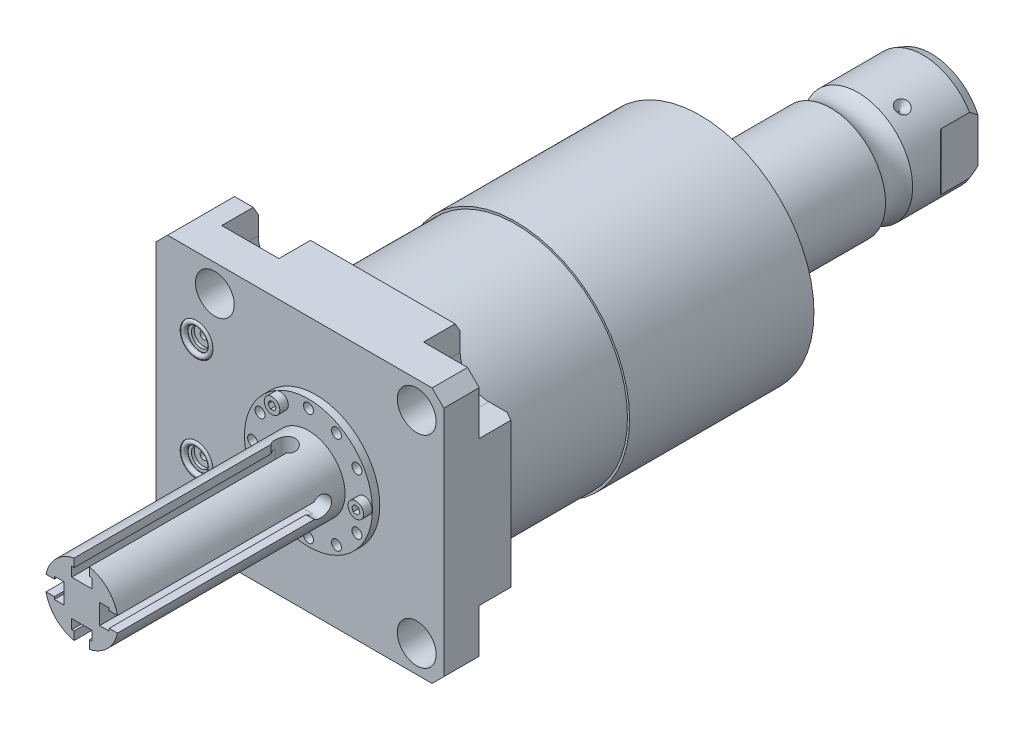
from build123d import *

# Parameters (mm, degrees)
SKETCH1_W                   = 100
SKETCH1_H                   = 88.9
EXTRUDE1_DEPTH              = 25.019
HOLE1_D                     = 13.487
CUT_EXTRUDE2_DEPTH          = 12.7
SKETCH6_R                   = 5.7023
CUT_EXTRUDE3_DEPTH          = 1.4478
SKETCH7_R                   = 3.2512
CUT_EXTRUDE4_DEPTH          = 1.016
SKETCH8_R                   = 1.2446
CUT_EXTRUDE5_DEPTH          = 11.9888
SKETCH9_R                   = 0.9271
CHAMFER1_SIZE               = 4.064
CHAMFER2_SIZE               = 3.0226
CHAMFER2_SIZE2              = 1.745098924
CIRPATTERN1_COUNT           = 3
CUT_EXTRUDE8_DEPTH          = 45.45
CUT_EXTRUDE8_DEPTH_BACK     = 45.45
SKETCH36_R                  = 1.727203455
SKETCH36_R_2                = 1.727203454
CUT_EXTRUDE9_DEPTH          = 2.540005
SKETCH37_R                  = 2.70510541
EXTRUDE2_DEPTH              = 2.946405893
CUT_EXTRUDE10_DEPTH         = 2.032004064
CUT_EXTRUDE11_DEPTH         = 6.477012954
SKETCH40_W                  = 6.98501397
SKETCH40_H                  = 70.612
CUT_EXTRUDE12_DEPTH         = 3.302006604
CIRPATTERN2_COUNT           = 2
CIRPATTERN2_ANGLE           = 90
CIRPATTERN2_COPY_1_DEPTH    = 6.477012954
CIRPATTERN2_COPY_2_SKETCH_W = 6.98501397
CIRPATTERN2_COPY_2_SKETCH_H = 70.612
CIRPATTERN2_COPY_2_DEPTH    = 3.302006604


with BuildPart() as part:
    # Sketch1 → Extrude1 (new body)
    with BuildSketch(Plane.XY):
        with Locations((-5.55, 0)):
            Rectangle(SKETCH1_W, SKETCH1_H)
    extrude(amount=EXTRUDE1_DEPTH)

    # Hole1 (through all)
    with Locations(Plane(origin=(0, 0, 0), x_dir=(-1, 0, 0), z_dir=(0, 0, -1))):
        with Locations((-35.052, -35.052), (-35.052, 35.052), (35.052, 35.052), (35.052, -35.052)):
            Hole(HOLE1_D / 2)

    # Sketch3 → Cut-Extrude2 (cut)
    with BuildSketch(Plane(origin=(0, 0, 0), x_dir=(-1, 0, 0), z_dir=(0, 0, -1))):
        with BuildLine():
            Line((-35.052, -25.1205), (-44.45, -25.1205))
            Line((-44.45, -25.1205), (-44.45, -44.45))
            Line((-44.45, -44.45), (-25.1205, -44.45))
            Line((-25.1205, -44.45), (-25.1205, -35.052))
            ThreePointArc((-25.1205, -35.052), (-28.029369003, -28.029369003), (-35.052, -25.1205))
        make_face()
        with BuildLine():
            Line((-44.45, 25.1205), (-44.45, 44.45))
            Line((-44.45, 44.45), (-25.1205, 44.45))
            Line((-25.1205, 44.45), (-25.1205, 35.052))
            ThreePointArc((-25.1205, 35.052), (-28.029369003, 28.029369003), (-35.052, 25.1205))
            Line((-35.052, 25.1205), (-44.45, 25.1205))
        make_face()
        with BuildLine():
            Line((25.1205, 44.45), (25.1205, 35.052))
            ThreePointArc((25.1205, 35.052), (35.052, 25.1205), (44.9835, 35.052))
            Line((44.9835, 35.052), (44.9835, 44.45))
            Line((44.9835, 44.45), (25.1205, 44.45))
        make_face()
        with BuildLine():
            Line((44.9835, -44.45), (25.1205, -44.45))
            Line((25.1205, -44.45), (25.1205, -35.052))
            ThreePointArc((25.1205, -35.052), (35.052, -25.1205), (44.9835, -35.052))
            Line((44.9835, -35.052), (44.9835, -44.45))
        make_face()
    extrude(amount=-CUT_EXTRUDE2_DEPTH, mode=Mode.SUBTRACT)

    # Sketch23 → Cut-Revolve5 (revolve, cut)
    with BuildSketch(Plane.XY.offset(12.014), mode=Mode.PRIVATE) as cut_revolve5_sk:
        Polygon((-55.55, -23.749), (-55.296, -23.749), (-55.296, -19.6596), (-54.5848, -18.9484), (-41.1228, -18.9484), (-41.1228, -13.0048), (-55.55, -13.0048), align=None)
    cut_revolve5 = revolve(cut_revolve5_sk.sketch.rotate(Axis((-11.939660979, -13.0048, 12.014), (-1, 0, 0)), 180), axis=Axis((-11.939660979, -13.0048, 12.014), (-1, 0, 0)), mode=Mode.SUBTRACT)  # turned: the seam where the file's is

    # Mirror1: Cut-Revolve5 across plane
    add(cut_revolve5.mirror(Plane.ZX), mode=Mode.SUBTRACT)

    # Sketch6 → Cut-Extrude3 (cut)
    with BuildSketch(Plane.XY.offset(25.019)):
        with Locations((-41.402, -18.11)):
            Circle(SKETCH6_R)
        with Locations((-41.402, 18.11)):
            Circle(SKETCH6_R)
    extrude(amount=-CUT_EXTRUDE3_DEPTH, mode=Mode.SUBTRACT)

    # Sketch7 → Cut-Extrude4 (cut)
    with BuildSketch(Plane.XY.offset(23.5712)):
        with Locations((-41.402, 18.11)):
            Circle(SKETCH7_R)
        with Locations((-41.402, -18.11)):
            Circle(SKETCH7_R)
    extrude(amount=-CUT_EXTRUDE4_DEPTH, mode=Mode.SUBTRACT)

    # Sketch8 → Cut-Extrude5 (cut)
    with BuildSketch(Plane.XY.offset(22.5552)):
        with Locations((-41.402, 18.11)):
            Circle(SKETCH8_R)
        with Locations((-41.402, -18.11)):
            Circle(SKETCH8_R)
    extrude(amount=-CUT_EXTRUDE5_DEPTH, mode=Mode.SUBTRACT)

    # Chamfer1
    chamfer1_edges = [part.edges().sort_by_distance(p)[0] for p in [
        (-55.55, 44.45, 12.5095),
        (44.45, 44.45, 18.8595),
        (44.45, -44.45, 18.8595),
        (-55.55, -44.45, 12.5095),
    ]]
    chamfer(chamfer1_edges, length=CHAMFER1_SIZE)

    # Chamfer2
    chamfer2_edges = [part.edges().sort_by_distance(p)[0] for p in [
        (-48.23475, -44.45, 0),
        (44.45, 0, 0),
        (0, 44.45, 0),
        (-48.23475, 44.45, 0),
        (0, -44.45, 0),
    ]]
    chamfer2_side = [part.faces().sort_by_distance(p)[0] for p in [
        (-6.590555374, 0, 0),
    ]]
    chamfer(chamfer2_edges, length=CHAMFER2_SIZE, length2=CHAMFER2_SIZE2, reference=chamfer2_side[0])

    # Sketch24 → Revolve4 (revolve)
    with BuildSketch(Plane(origin=(0, 0, 0), x_dir=(0, 0, -1), z_dir=(1, 0, 0)), mode=Mode.PRIVATE) as revolve4_sk:
        Polygon((0, 0), (0, 38.786), (44.45, 38.786), (44.45, 39.5225), (108.48388753, 39.5225), (112.268, 25.4), (112.268, 0), align=None)
    revolve(revolve4_sk.sketch.rotate(Axis((0, 0, 0), (0, 0, -1)), 90), axis=Axis((0, 0, 0), (0, 0, -1)))  # turned: the seam where the file's is

    # Sketch17 → Revolve3 (revolve)
    with BuildSketch(Plane(origin=(0, 0, 0), x_dir=(0, 0, -1), z_dir=(1, 0, 0)), mode=Mode.PRIVATE) as revolve3_sk:
        with BuildLine():
            Line((112.268, 0), (112.268, -19.05))
            Line((112.268, -19.05), (153.81490643, -19.05))
            ThreePointArc((153.81490643, -19.05), (158.522, -17.5006), (163.22909357, -19.05))
            Line((163.22909357, -19.05), (185.77599416, -19.05))
            Line((185.77599416, -19.05), (188.697, -17.98684082))
            Line((188.697, -17.98684082), (188.697, 0))
            Line((188.697, 0), (112.268, 0))
        make_face()
    revolve(revolve3_sk.sketch.rotate(Axis((0, 0, -130.8989), (0, 0, 1)), 270), axis=Axis((0, 0, -130.8989), (0, 0, 1)))  # turned: the seam where the file's is

    # Sketch28 → Cut-Revolve6 (revolve, cut)
    with BuildSketch(Plane(origin=(0, 0, 0), x_dir=(1, 0, 0), z_dir=(0, 1, 0)), mode=Mode.PRIVATE) as cut_revolve6_sk:
        Polygon((-19.05, 171.603), (-16.637, 169.19), (-19.05, 169.19), align=None)
    cut_revolve6 = revolve(cut_revolve6_sk.sketch.rotate(Axis((-34.306164512, 0, -169.19), (1, 0, 0)), 180), axis=Axis((-34.306164512, 0, -169.19), (1, 0, 0)), mode=Mode.SUBTRACT)  # turned: the seam where the file's is

    # CirPattern1: Cut-Revolve6 ×3 about axis
    cirpattern1_axis = Axis((0, 0, -130.8989), (0, 0, -1))
    for i in range(1, CIRPATTERN1_COUNT):
        add(cut_revolve6.rotate(cirpattern1_axis, i * 360 / CIRPATTERN1_COUNT), mode=Mode.SUBTRACT)

    # Sketch32 → Hole2 (revolve, cut)
    with BuildSketch(Plane(origin=(0, 0, -188.697), x_dir=(0, 1, 0), z_dir=(1, 0, 0))):
        Polygon((0, 0), (0, 29.566487704), (6.9342, 25.4), (6.9342, 0), align=None)
    revolve(axis=Axis((0, 0, -192.941199587), (0, 0, 1)), mode=Mode.SUBTRACT)

    # Sketch34 → Cut-Extrude8 (cut, two sides)
    with BuildSketch(Plane(origin=(0, 0, 0), x_dir=(0, 0, -1), z_dir=(0, 1, 0))) as cut_extrude8_sk:
        with BuildLine():
            Line((172.912868636, 19.05), (175.458183558, 16.504685078))
            ThreePointArc((175.458183558, 16.504685078), (175.705394643, 16.339503912), (175.997, 16.2815))
            Line((175.997, 16.2815), (188.697, 16.2815))
            Line((188.697, 16.2815), (188.697, 19.05))
            Line((188.697, 19.05), (172.912868636, 19.05))
        make_face()
        with BuildLine():
            Line((188.697, -19.05), (172.912868636, -19.05))
            Line((172.912868636, -19.05), (175.458183558, -16.504685078))
            ThreePointArc((175.458183558, -16.504685078), (175.705394643, -16.339503912), (175.997, -16.2815))
            Line((175.997, -16.2815), (188.697, -16.2815))
            Line((188.697, -16.2815), (188.697, -19.05))
        make_face()
    extrude(amount=CUT_EXTRUDE8_DEPTH, mode=Mode.SUBTRACT)
    extrude(cut_extrude8_sk.sketch, amount=-CUT_EXTRUDE8_DEPTH_BACK, mode=Mode.SUBTRACT)

    # Sketch35 → Revolve5 (revolve)
    with BuildSketch(Plane(origin=(0, 0, 0), x_dir=(1, 0, 0), z_dir=(0, 1, 0)), mode=Mode.PRIVATE) as revolve5_sk:
        Polygon((0, -25.019), (22.22504445, -25.019), (22.22504445, -27.55900508), (12.7, -27.55900508), (12.7, -106.299), (0, -106.299), align=None)
    revolve(revolve5_sk.sketch.rotate(Axis((0, 0, 985.690504339), (0, 0, -1)), 180), axis=Axis((0, 0, 985.690504339), (0, 0, -1)))  # turned: the seam where the file's is

    # Sketch36 → Cut-Extrude9 (cut)
    with BuildSketch(Plane.XY.offset(27.55900508)):
        with Locations((19.400503009, 0)):
            Circle(SKETCH36_R)
        with Locations((16.827773276, 9.715519431)):
            Circle(SKETCH36_R)
        with Locations((9.715519431, 16.827773276)):
            Circle(SKETCH36_R)
        with Locations((0, 19.431038862)):
            Circle(SKETCH36_R_2)
        with Locations(Location((-9.715519431, 16.827773276, 0), (0, 0, 180))):  # turned: the seam where the file's is
            Circle(SKETCH36_R)
        with Locations(Location((-16.827773276, 9.715519431, 0), (0, 0, 180))):  # turned: the seam where the file's is
            Circle(SKETCH36_R)
        with Locations(Location((-19.400503009, 0, 0), (0, 0, 180))):  # turned: the seam where the file's is
            Circle(SKETCH36_R)
        with Locations((-16.827773276, -9.715519431)):
            Circle(SKETCH36_R)
        with Locations((-9.715519431, -16.827773276)):
            Circle(SKETCH36_R)
        with Locations(Location((0, -19.431038862, 0), (0, 0, 180))):  # turned: the seam where the file's is
            Circle(SKETCH36_R_2)
        with Locations(Location((9.715519431, -16.827773276, 0), (0, 0, 180))):  # turned: the seam where the file's is
            Circle(SKETCH36_R)
        with Locations(Location((16.827773276, -9.715519431, 0), (0, 0, 180))):  # turned: the seam where the file's is
            Circle(SKETCH36_R)
    extrude(amount=-CUT_EXTRUDE9_DEPTH, mode=Mode.SUBTRACT)

    # Sketch37 → Extrude2 (add)
    with BuildSketch(Plane.XY.offset(27.55900508)):
        with Locations((19.400503009, 0)):
            Circle(SKETCH37_R)
        with Locations((-9.715519431, 16.827773276)):
            Circle(SKETCH37_R)
        with Locations((-9.715519431, -16.827773276)):
            Circle(SKETCH37_R)
    extrude(amount=EXTRUDE2_DEPTH)

    # Sketch38 → Cut-Extrude10 (cut)
    with BuildSketch(Plane.XY.offset(30.505410973)):
        Polygon((19.864679682, -1.366701631), (20.816189677, -0.281362025), (20.352013004, 1.085339606), (18.936326336, 1.366701631), (17.98481634, 0.281362025), (18.448993013, -1.085339606), align=None)
        Polygon((-8.848997808, 15.673445069), (-8.282581068, 17.001038911), (-9.14910269, 18.155367118), (-10.582041054, 17.982101484), (-11.148457794, 16.654507642), (-10.281936172, 15.500179434), align=None)
        Polygon((-9.365034361, -18.227949533), (-8.327688688, -17.22433243), (-8.678173759, -15.824156174), (-10.066004501, -15.42759702), (-11.103350174, -16.431214123), (-10.752865104, -17.831390379), align=None)
    extrude(amount=-CUT_EXTRUDE10_DEPTH, mode=Mode.SUBTRACT)

    # Sketch39 → Cut-Extrude11 (cut)
    with BuildSketch(Plane(origin=(0, 12.7, 66.92900254), x_dir=(-1, 0, 0), z_dir=(0, 1, 0))):
        with BuildLine():
            Line((-2.641605283, 39.36999746), (-2.641605283, -28.957384896))
            ThreePointArc((-2.641605283, -28.957384896), (0, -34.73450254), (2.641605283, -28.957384896))
            Line((2.641605283, -28.957384896), (2.641605283, 39.36999746))
            Line((2.641605283, 39.36999746), (-2.641605283, 39.36999746))
        make_face()
    cut_extrude11 = extrude(amount=-CUT_EXTRUDE11_DEPTH, mode=Mode.SUBTRACT)

    # Sketch40 → Cut-Extrude12 (cut)
    with BuildSketch(Plane(origin=(0, 6.222987046, 0), x_dir=(1, 0, 0), z_dir=(0, 1, 0))):
        with Locations((0, -70.993)):
            Rectangle(SKETCH40_W, SKETCH40_H)
    cut_extrude12 = extrude(amount=CUT_EXTRUDE12_DEPTH, mode=Mode.SUBTRACT)

    # Mirror3: Cut-Extrude11, Cut-Extrude12 across plane
    add(cut_extrude11.mirror(Plane.ZX), mode=Mode.SUBTRACT)
    add(cut_extrude12.mirror(Plane.ZX), mode=Mode.SUBTRACT)

    # CirPattern2: Cut-Extrude11, Cut-Extrude12 ×2 about axis
    cirpattern2_axis = Axis((0, 0, 0), (0, 0, 1))
    add([cut_extrude11.rotate(cirpattern2_axis, i * CIRPATTERN2_ANGLE / (CIRPATTERN2_COUNT - 1)) for i in range(1, CIRPATTERN2_COUNT)], mode=Mode.SUBTRACT)
    add([cut_extrude12.rotate(cirpattern2_axis, i * CIRPATTERN2_ANGLE / (CIRPATTERN2_COUNT - 1)) for i in range(1, CIRPATTERN2_COUNT)], mode=Mode.SUBTRACT)

    # CirPattern2 copy 1 sketch → CirPattern2 copy 1 (cut)
    with BuildSketch(Plane(origin=(12.7, 0, 66.92900254), x_dir=(0, -1, 0), z_dir=(1, 0, 0))):
        with BuildLine():
            Line((-2.641605283, -39.36999746), (-2.641605283, 28.957384896))
            ThreePointArc((-2.641605283, 28.957384896), (0, 34.73450254), (2.641605283, 28.957384896))
            Line((2.641605283, 28.957384896), (2.641605283, -39.36999746))
            Line((2.641605283, -39.36999746), (-2.641605283, -39.36999746))
        make_face()
    extrude(amount=-CIRPATTERN2_COPY_1_DEPTH, mode=Mode.SUBTRACT)

    # CirPattern2 copy 2 sketch → CirPattern2 copy 2 (cut)
    with BuildSketch(Plane.YZ.offset(6.222987046)):
        with Locations((0, 70.993)):
            Rectangle(CIRPATTERN2_COPY_2_SKETCH_W, CIRPATTERN2_COPY_2_SKETCH_H)
    extrude(amount=CIRPATTERN2_COPY_2_DEPTH, mode=Mode.SUBTRACT)


with BuildPart() as body_2:
    # Sketch9 → Revolve1 (revolve)
    with BuildSketch(Plane(origin=(-41.656, 18.11, 23.5712), x_dir=(1, 0, 0), z_dir=(0, 1, 0))):
        with Locations((5.0292, -0.9271)):
            Circle(SKETCH9_R)
    revolve(axis=Axis((-41.402, 18.11, 25.51811), (0, 0, -1)))


with BuildPart() as body_3:
    # Mirror2: mirrored copy
    add(body_2.part.mirror(Plane.ZX))


solid = Compound([part.part, body_2.part, body_3.part])
